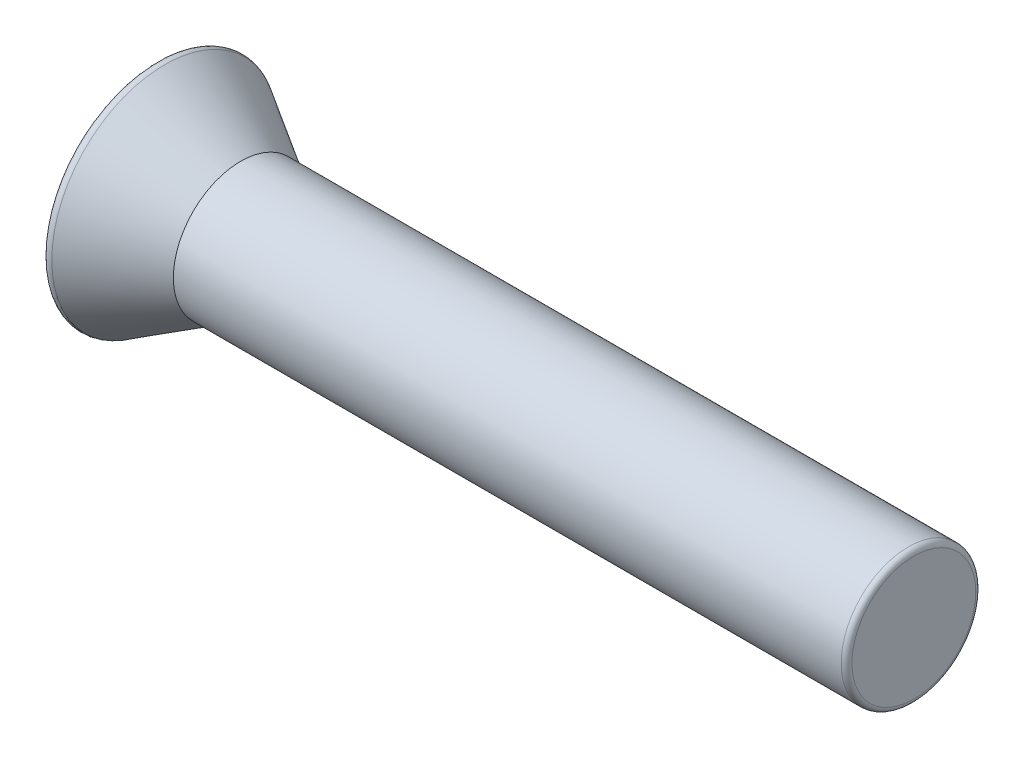
from build123d import *

# Parameters (mm, degrees)
FILLET_1_R          = 0.16
SKETCH_2_R          = 2
EXTRUDE_1_DEPTH     = 20
FILLET_2_R          = 0.16
CUT_EXTRUDE_1_DEPTH = 1


with BuildPart() as part:
    # 草图1 → 旋转1 (revolve)
    with BuildSketch(Plane.XY):
        Polygon((0, 0), (0, 3.5), (2.5, 2), (2.5, 0), align=None)
    revolve(axis=Axis((0, 0, 0), (-1, 0, 0)))

    # 圆角1
    fillet_1_edges = [part.edges().sort_by_distance(p)[0] for p in [
        (0, -3.5, 0),
    ]]
    fillet(fillet_1_edges, radius=FILLET_1_R)

    # 草图2 → 凸台-拉伸1 (add)
    with BuildSketch(Plane(origin=(2.5, 0, 0), x_dir=(0, 0, -1), z_dir=(1, 0, 0))):
        Circle(SKETCH_2_R)
    extrude(amount=EXTRUDE_1_DEPTH)

    # 圆角2
    fillet_2_edges = [part.edges().sort_by_distance(p)[0] for p in [
        (22.5, 0, 2),
    ]]
    fillet(fillet_2_edges, radius=FILLET_2_R)

    # 草图3 → 切除-拉伸1 (cut)
    with BuildSketch(Plane.ZY):
        Polygon((0.41, -0.41), (0.41, -2.15), (-0.41, -2.15), (-0.41, -0.41), (-2.15, -0.41), (-2.15, 0.41), (-0.41, 0.41), (-0.41, 2.15), (0.41, 2.15), (0.41, 0.41), (2.15, 0.41), (2.15, -0.41), align=None)
    extrude(amount=-CUT_EXTRUDE_1_DEPTH, mode=Mode.SUBTRACT)


solid = part.part
